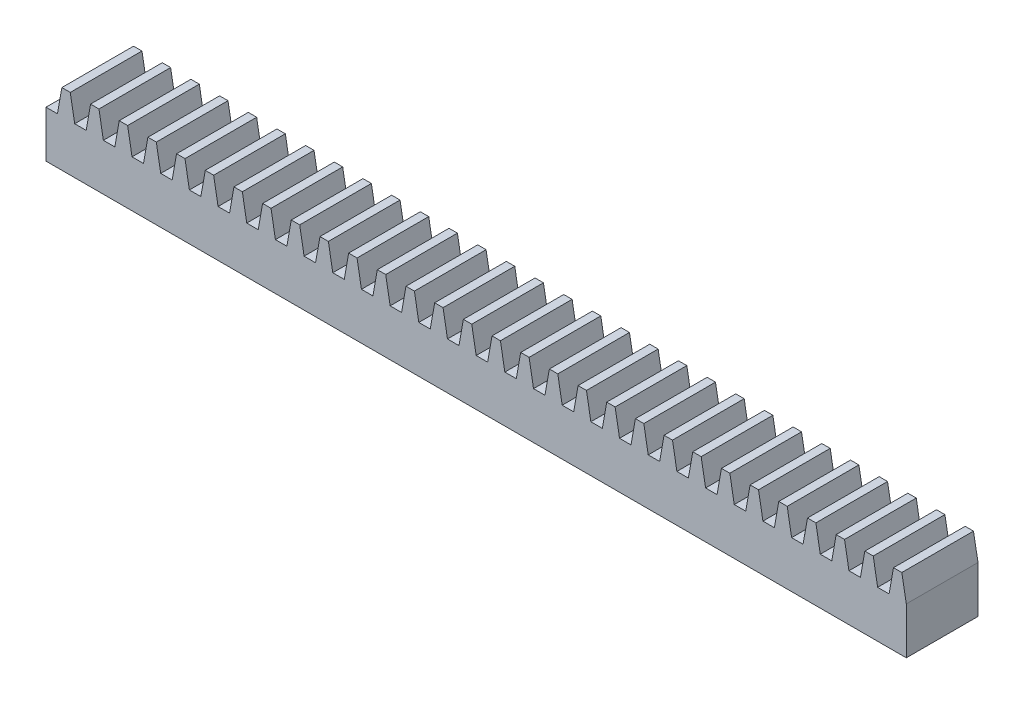
from build123d import *

# Parameters (mm, degrees)
SKETCH1_W           = 6.35
SKETCH1_H           = 6.35
BOSS_EXTRUDE1_DEPTH = 76.2
CUT_EXTRUDE1_DEPTH  = 76.2
SKETCH3_R           = 1.3462
CUT_EXTRUDE2_DEPTH  = 4.572


with BuildPart() as part:
    # Sketch1 → Boss-Extrude1 (new body)
    with BuildSketch(Plane(origin=(0, 0, 0), x_dir=(0, 0, -1), z_dir=(1, 0, 0))):
        with Locations((3.175, 3.175)):
            Rectangle(SKETCH1_W, SKETCH1_H)
    extrude(amount=-BOSS_EXTRUDE1_DEPTH)

    # Sketch2 → Cut-Extrude1 (cut)
    with BuildSketch(Plane.XY):
        Polygon((-5.08, 4.1402), (-5.469647362, 6.35), (-3.674352638, 6.35), (-4.064, 4.1402), align=None)
        Polygon((-1.524, 4.1402), (-1.134352638, 6.35), (-2.929647362, 6.35), (-2.54, 4.1402), align=None)
        Polygon((-7.62, 4.1402), (-8.009647362, 6.35), (-6.214352638, 6.35), (-6.604, 4.1402), align=None)
        Polygon((-10.16, 4.1402), (-10.549647362, 6.35), (-8.754352638, 6.35), (-9.144, 4.1402), align=None)
        Polygon((-12.7, 4.1402), (-13.089647362, 6.35), (-11.294352638, 6.35), (-11.684, 4.1402), align=None)
        Polygon((-15.24, 4.1402), (-15.629647362, 6.35), (-13.834352638, 6.35), (-14.224, 4.1402), align=None)
        Polygon((-17.78, 4.1402), (-18.169647362, 6.35), (-16.374352638, 6.35), (-16.764, 4.1402), align=None)
        Polygon((-20.32, 4.1402), (-20.709647362, 6.35), (-18.914352638, 6.35), (-19.304, 4.1402), align=None)
        Polygon((-22.86, 4.1402), (-23.249647362, 6.35), (-21.454352638, 6.35), (-21.844, 4.1402), align=None)
        Polygon((-25.4, 4.1402), (-25.789647362, 6.35), (-23.994352638, 6.35), (-24.384, 4.1402), align=None)
        Polygon((-27.94, 4.1402), (-28.329647362, 6.35), (-26.534352638, 6.35), (-26.924, 4.1402), align=None)
        Polygon((-30.48, 4.1402), (-30.869647362, 6.35), (-29.074352638, 6.35), (-29.464, 4.1402), align=None)
        Polygon((-33.02, 4.1402), (-33.409647362, 6.35), (-31.614352638, 6.35), (-32.004, 4.1402), align=None)
        Polygon((-35.56, 4.1402), (-35.949647362, 6.35), (-34.154352638, 6.35), (-34.544, 4.1402), align=None)
        Polygon((-38.1, 4.1402), (-38.489647362, 6.35), (-36.694352638, 6.35), (-37.084, 4.1402), align=None)
        Polygon((-40.64, 4.1402), (-41.029647362, 6.35), (-39.234352638, 6.35), (-39.624, 4.1402), align=None)
        Polygon((-43.18, 4.1402), (-43.569647362, 6.35), (-41.774352638, 6.35), (-42.164, 4.1402), align=None)
        Polygon((-45.72, 4.1402), (-46.109647362, 6.35), (-44.314352638, 6.35), (-44.704, 4.1402), align=None)
        Polygon((-48.26, 4.1402), (-48.649647362, 6.35), (-46.854352638, 6.35), (-47.244, 4.1402), align=None)
        Polygon((-50.8, 4.1402), (-51.189647362, 6.35), (-49.394352638, 6.35), (-49.784, 4.1402), align=None)
        Polygon((-53.34, 4.1402), (-53.729647362, 6.35), (-51.934352638, 6.35), (-52.324, 4.1402), align=None)
        Polygon((-55.88, 4.1402), (-56.269647362, 6.35), (-54.474352638, 6.35), (-54.864, 4.1402), align=None)
        Polygon((-58.42, 4.1402), (-58.809647362, 6.35), (-57.014352638, 6.35), (-57.404, 4.1402), align=None)
        Polygon((-60.96, 4.1402), (-61.349647362, 6.35), (-59.554352638, 6.35), (-59.944, 4.1402), align=None)
        Polygon((-63.5, 4.1402), (-63.889647362, 6.35), (-62.094352638, 6.35), (-62.484, 4.1402), align=None)
        Polygon((-66.04, 4.1402), (-66.429647362, 6.35), (-64.634352638, 6.35), (-65.024, 4.1402), align=None)
        Polygon((-68.58, 4.1402), (-68.969647362, 6.35), (-67.174352638, 6.35), (-67.564, 4.1402), align=None)
        Polygon((-71.12, 4.1402), (-71.509647362, 6.35), (-69.714352638, 6.35), (-70.104, 4.1402), align=None)
        Polygon((-73.66, 4.1402), (-74.049647362, 6.35), (-72.254352638, 6.35), (-72.644, 4.1402), align=None)
        Polygon((-76.2, 4.1402), (-76.589647362, 6.35), (-74.794352638, 6.35), (-75.184, 4.1402), align=None)
        Polygon((-78.74, 4.1402), (-79.129647362, 6.35), (-77.334352638, 6.35), (-77.724, 4.1402), align=None)
        Polygon((-81.28, 4.1402), (-81.669647362, 6.35), (-79.874352638, 6.35), (-80.264, 4.1402), align=None)
        Polygon((-83.82, 4.1402), (-84.209647362, 6.35), (-82.414352638, 6.35), (-82.804, 4.1402), align=None)
        Polygon((-86.36, 4.1402), (-86.749647362, 6.35), (-84.954352638, 6.35), (-85.344, 4.1402), align=None)
        Polygon((-88.9, 4.1402), (-89.289647362, 6.35), (-87.494352638, 6.35), (-87.884, 4.1402), align=None)
        Polygon((-91.44, 4.1402), (-91.829647362, 6.35), (-90.034352638, 6.35), (-90.424, 4.1402), align=None)
        Polygon((-93.98, 4.1402), (-94.369647362, 6.35), (-92.574352638, 6.35), (-92.964, 4.1402), align=None)
        Polygon((-96.52, 4.1402), (-96.909647362, 6.35), (-95.114352638, 6.35), (-95.504, 4.1402), align=None)
        Polygon((-99.06, 4.1402), (-99.449647362, 6.35), (-97.654352638, 6.35), (-98.044, 4.1402), align=None)
        Polygon((-101.6, 4.1402), (-101.989647362, 6.35), (-100.194352638, 6.35), (-100.584, 4.1402), align=None)
        Polygon((-104.14, 4.1402), (-104.529647362, 6.35), (-102.734352638, 6.35), (-103.124, 4.1402), align=None)
        Polygon((-106.68, 4.1402), (-107.069647362, 6.35), (-105.274352638, 6.35), (-105.664, 4.1402), align=None)
        Polygon((-109.22, 4.1402), (-109.609647362, 6.35), (-107.814352638, 6.35), (-108.204, 4.1402), align=None)
        Polygon((-111.76, 4.1402), (-112.149647362, 6.35), (-110.354352638, 6.35), (-110.744, 4.1402), align=None)
        Polygon((-114.3, 4.1402), (-114.689647362, 6.35), (-112.894352638, 6.35), (-113.284, 4.1402), align=None)
        Polygon((-116.84, 4.1402), (-117.229647362, 6.35), (-115.434352638, 6.35), (-115.824, 4.1402), align=None)
        Polygon((-119.38, 4.1402), (-119.769647362, 6.35), (-117.974352638, 6.35), (-118.364, 4.1402), align=None)
        Polygon((-121.92, 4.1402), (-122.309647362, 6.35), (-120.514352638, 6.35), (-120.904, 4.1402), align=None)
        Polygon((-124.46, 4.1402), (-124.849647362, 6.35), (-123.054352638, 6.35), (-123.444, 4.1402), align=None)
        Polygon((-127, 4.1402), (-127.389647362, 6.35), (-125.594352638, 6.35), (-125.984, 4.1402), align=None)
        Polygon((-129.54, 4.1402), (-129.929647362, 6.35), (-128.134352638, 6.35), (-128.524, 4.1402), align=None)
        Polygon((-132.08, 4.1402), (-132.469647362, 6.35), (-130.674352638, 6.35), (-131.064, 4.1402), align=None)
        Polygon((-134.62, 4.1402), (-135.009647362, 6.35), (-133.214352638, 6.35), (-133.604, 4.1402), align=None)
        Polygon((-137.16, 4.1402), (-137.549647362, 6.35), (-135.754352638, 6.35), (-136.144, 4.1402), align=None)
        Polygon((-139.7, 4.1402), (-140.089647362, 6.35), (-138.294352638, 6.35), (-138.684, 4.1402), align=None)
        Polygon((-142.24, 4.1402), (-142.629647362, 6.35), (-140.834352638, 6.35), (-141.224, 4.1402), align=None)
        Polygon((-144.78, 4.1402), (-145.169647362, 6.35), (-143.374352638, 6.35), (-143.764, 4.1402), align=None)
        Polygon((-147.32, 4.1402), (-147.709647362, 6.35), (-145.914352638, 6.35), (-146.304, 4.1402), align=None)
        Polygon((-149.86, 4.1402), (-150.249647362, 6.35), (-148.454352638, 6.35), (-148.844, 4.1402), align=None)
        Polygon((-152.4, 4.1402), (-152.789647362, 6.35), (-150.994352638, 6.35), (-151.384, 4.1402), align=None)
        Polygon((-154.94, 4.1402), (-155.329647362, 6.35), (-153.534352638, 6.35), (-153.924, 4.1402), align=None)
        Polygon((-157.48, 4.1402), (-157.869647362, 6.35), (-156.074352638, 6.35), (-156.464, 4.1402), align=None)
        Polygon((-160.02, 4.1402), (-160.409647362, 6.35), (-158.614352638, 6.35), (-159.004, 4.1402), align=None)
        Polygon((-162.56, 4.1402), (-162.949647362, 6.35), (-161.154352638, 6.35), (-161.544, 4.1402), align=None)
        Polygon((-165.1, 4.1402), (-165.489647362, 6.35), (-163.694352638, 6.35), (-164.084, 4.1402), align=None)
        Polygon((-167.64, 4.1402), (-168.029647362, 6.35), (-166.234352638, 6.35), (-166.624, 4.1402), align=None)
        Polygon((-170.18, 4.1402), (-170.569647362, 6.35), (-168.774352638, 6.35), (-169.164, 4.1402), align=None)
        Polygon((-172.72, 4.1402), (-173.109647362, 6.35), (-171.314352638, 6.35), (-171.704, 4.1402), align=None)
        Polygon((-175.26, 4.1402), (-175.649647362, 6.35), (-173.854352638, 6.35), (-174.244, 4.1402), align=None)
        Polygon((-177.8, 4.1402), (-178.189647362, 6.35), (-176.394352638, 6.35), (-176.784, 4.1402), align=None)
        Polygon((-180.34, 4.1402), (-180.729647362, 6.35), (-178.934352638, 6.35), (-179.324, 4.1402), align=None)
        Polygon((-182.88, 4.1402), (-183.269647362, 6.35), (-181.474352638, 6.35), (-181.864, 4.1402), align=None)
        Polygon((-185.42, 4.1402), (-185.809647362, 6.35), (-184.014352638, 6.35), (-184.404, 4.1402), align=None)
        Polygon((-187.96, 4.1402), (-188.349647362, 6.35), (-186.554352638, 6.35), (-186.944, 4.1402), align=None)
        Polygon((-190.5, 4.1402), (-190.889647362, 6.35), (-189.094352638, 6.35), (-189.484, 4.1402), align=None)
        Polygon((-193.04, 4.1402), (-193.429647362, 6.35), (-191.634352638, 6.35), (-192.024, 4.1402), align=None)
        Polygon((-195.58, 4.1402), (-195.969647362, 6.35), (-194.174352638, 6.35), (-194.564, 4.1402), align=None)
        Polygon((-198.12, 4.1402), (-198.509647362, 6.35), (-196.714352638, 6.35), (-197.104, 4.1402), align=None)
        Polygon((-200.66, 4.1402), (-201.049647362, 6.35), (-199.254352638, 6.35), (-199.644, 4.1402), align=None)
        Polygon((-203.2, 4.1402), (-203.589647362, 6.35), (-201.794352638, 6.35), (-202.184, 4.1402), align=None)
        Polygon((-205.74, 4.1402), (-206.129647362, 6.35), (-204.334352638, 6.35), (-204.724, 4.1402), align=None)
        Polygon((-208.28, 4.1402), (-208.669647362, 6.35), (-206.874352638, 6.35), (-207.264, 4.1402), align=None)
        Polygon((-210.82, 4.1402), (-211.209647362, 6.35), (-209.414352638, 6.35), (-209.804, 4.1402), align=None)
        Polygon((-213.36, 4.1402), (-213.749647362, 6.35), (-211.954352638, 6.35), (-212.344, 4.1402), align=None)
        Polygon((-215.9, 4.1402), (-216.289647362, 6.35), (-214.494352638, 6.35), (-214.884, 4.1402), align=None)
        Polygon((-218.44, 4.1402), (-218.829647362, 6.35), (-217.034352638, 6.35), (-217.424, 4.1402), align=None)
        Polygon((-220.98, 4.1402), (-221.369647362, 6.35), (-219.574352638, 6.35), (-219.964, 4.1402), align=None)
        Polygon((-223.52, 4.1402), (-223.909647362, 6.35), (-222.114352638, 6.35), (-222.504, 4.1402), align=None)
        Polygon((-226.06, 4.1402), (-226.449647362, 6.35), (-224.654352638, 6.35), (-225.044, 4.1402), align=None)
        Polygon((-228.6, 4.1402), (-228.989647362, 6.35), (-227.194352638, 6.35), (-227.584, 4.1402), align=None)
        Polygon((-231.14, 4.1402), (-231.529647362, 6.35), (-229.734352638, 6.35), (-230.124, 4.1402), align=None)
        Polygon((-233.68, 4.1402), (-234.069647362, 6.35), (-232.274352638, 6.35), (-232.664, 4.1402), align=None)
        Polygon((-236.22, 4.1402), (-236.609647362, 6.35), (-234.814352638, 6.35), (-235.204, 4.1402), align=None)
        Polygon((-238.76, 4.1402), (-239.149647362, 6.35), (-237.354352638, 6.35), (-237.744, 4.1402), align=None)
        Polygon((-241.3, 4.1402), (-241.689647362, 6.35), (-239.894352638, 6.35), (-240.284, 4.1402), align=None)
        Polygon((-243.84, 4.1402), (-244.229647362, 6.35), (-242.434352638, 6.35), (-242.824, 4.1402), align=None)
        Polygon((-246.38, 4.1402), (-246.769647362, 6.35), (-244.974352638, 6.35), (-245.364, 4.1402), align=None)
        Polygon((-248.92, 4.1402), (-249.309647362, 6.35), (-247.514352638, 6.35), (-247.904, 4.1402), align=None)
        Polygon((-251.46, 4.1402), (-251.849647362, 6.35), (-250.054352638, 6.35), (-250.444, 4.1402), align=None)
        Polygon((-254, 4.1402), (-254.389647362, 6.35), (-252.594352638, 6.35), (-252.984, 4.1402), align=None)
        Polygon((-256.54, 4.1402), (-256.929647362, 6.35), (-255.134352638, 6.35), (-255.524, 4.1402), align=None)
        Polygon((-259.08, 4.1402), (-259.469647362, 6.35), (-257.674352638, 6.35), (-258.064, 4.1402), align=None)
        Polygon((-261.62, 4.1402), (-262.009647362, 6.35), (-260.214352638, 6.35), (-260.604, 4.1402), align=None)
        Polygon((-264.16, 4.1402), (-264.549647362, 6.35), (-262.754352638, 6.35), (-263.144, 4.1402), align=None)
        Polygon((-266.7, 4.1402), (-267.089647362, 6.35), (-265.294352638, 6.35), (-265.684, 4.1402), align=None)
        Polygon((-269.24, 4.1402), (-269.629647362, 6.35), (-267.834352638, 6.35), (-268.224, 4.1402), align=None)
        Polygon((-271.78, 4.1402), (-272.169647362, 6.35), (-270.374352638, 6.35), (-270.764, 4.1402), align=None)
        Polygon((-274.32, 4.1402), (-274.709647362, 6.35), (-272.914352638, 6.35), (-273.304, 4.1402), align=None)
        Polygon((-276.86, 4.1402), (-277.249647362, 6.35), (-275.454352638, 6.35), (-275.844, 4.1402), align=None)
        Polygon((-279.4, 4.1402), (-279.789647362, 6.35), (-277.994352638, 6.35), (-278.384, 4.1402), align=None)
        Polygon((-281.94, 4.1402), (-282.329647362, 6.35), (-280.534352638, 6.35), (-280.924, 4.1402), align=None)
        Polygon((-284.48, 4.1402), (-284.869647362, 6.35), (-283.074352638, 6.35), (-283.464, 4.1402), align=None)
        Polygon((-287.02, 4.1402), (-287.409647362, 6.35), (-285.614352638, 6.35), (-286.004, 4.1402), align=None)
        Polygon((-289.56, 4.1402), (-289.949647362, 6.35), (-288.154352638, 6.35), (-288.544, 4.1402), align=None)
        Polygon((-292.1, 4.1402), (-292.489647362, 6.35), (-290.694352638, 6.35), (-291.084, 4.1402), align=None)
        Polygon((-294.64, 4.1402), (-295.029647362, 6.35), (-293.234352638, 6.35), (-293.624, 4.1402), align=None)
        Polygon((-297.18, 4.1402), (-297.569647362, 6.35), (-295.774352638, 6.35), (-296.164, 4.1402), align=None)
        Polygon((-299.72, 4.1402), (-300.109647362, 6.35), (-298.314352638, 6.35), (-298.704, 4.1402), align=None)
        Polygon((-302.26, 4.1402), (-302.649647362, 6.35), (-300.854352638, 6.35), (-301.244, 4.1402), align=None)
        Polygon((-304.8, 4.1402), (-305.189647362, 6.35), (-303.394352638, 6.35), (-303.784, 4.1402), align=None)
        Polygon((-0.397752638, 6.35), (0, 6.35), (0, 4.1402), align=None)
    extrude(amount=-CUT_EXTRUDE1_DEPTH, mode=Mode.SUBTRACT)

    # Sketch3 → Cut-Extrude2 (cut)
    with BuildSketch(Plane.XZ):
        with Locations((-19.05, -3.175)):
            Circle(SKETCH3_R)
    extrude(amount=-CUT_EXTRUDE2_DEPTH, mode=Mode.SUBTRACT)


solid = part.part
